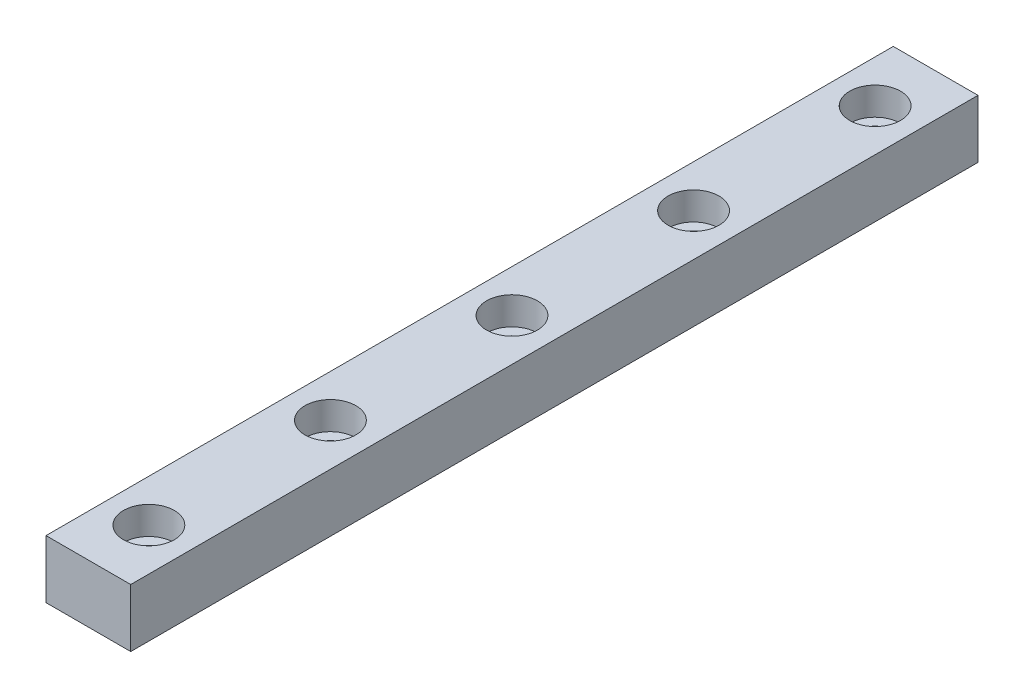
from build123d import *

# Parameters (mm, degrees)
SKETCH1_W                      = 7
SKETCH1_H                      = 4.8
BOSS_EXTRUDE1_DEPTH            = 70
CBORE_FOR_M2_SHCS1_D           = 2.4
CBORE_FOR_M2_SHCS1_CBORE_D     = 4.2
CBORE_FOR_M2_SHCS1_CBORE_DEPTH = 2.3


with BuildPart() as part:
    # Sketch1 → Boss-Extrude1 (new body)
    with BuildSketch(Plane.XY):
        with Locations((3.5, 2.4)):
            Rectangle(SKETCH1_W, SKETCH1_H)
    extrude(amount=BOSS_EXTRUDE1_DEPTH)

    # CBORE for M2 SHCS1 (through all)
    with Locations(Plane(origin=(0, 4.8, 0), x_dir=(1, 0, 0), z_dir=(0, 1, 0))):
        with Locations((3.5, -65), (3.5, -50), (3.5, -35), (3.5, -20), (3.5, -5)):
            CounterBoreHole(CBORE_FOR_M2_SHCS1_D / 2, CBORE_FOR_M2_SHCS1_CBORE_D / 2, CBORE_FOR_M2_SHCS1_CBORE_DEPTH)


solid = part.part
